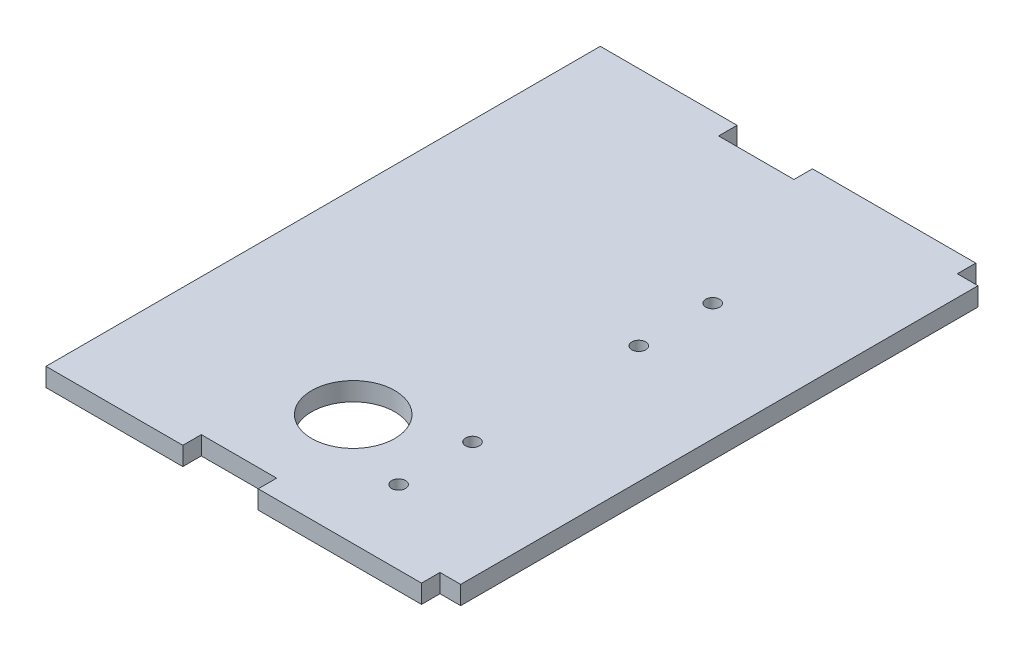
from build123d import *

# Parameters (mm, degrees)
SKETCH1_W           = 304.8
SKETCH1_H           = 355.6
SKETCH1_RX          = 28.575
SKETCH1_RY          = 28.573991153
BOSS_EXTRUDE1_DEPTH = 12.7
SKETCH2_R           = 4.7625
CUT_EXTRUDE1_DEPTH  = 12.7
SKETCH3_W           = 112.268
SKETCH3_H           = 12.7
BOSS_EXTRUDE2_DEPTH = 12.7
SKETCH5_W           = 38.383719954
SKETCH5_H           = 381
CUT_EXTRUDE2_DEPTH  = 13.7


with BuildPart() as part:
    # Sketch1 → Boss-Extrude1 (new body)
    with BuildSketch(Plane(origin=(0, 0, 0), x_dir=(1, 0, 0), z_dir=(0, 1, 0))):
        with Locations((152.4, 177.8)):
            Rectangle(SKETCH1_W, SKETCH1_H)
        with Locations(Location((166.724174942, 64.195003676), (0, 0, 0))):
            Ellipse(SKETCH1_RX, SKETCH1_RY, mode=Mode.SUBTRACT)
    extrude(amount=BOSS_EXTRUDE1_DEPTH)

    # Sketch2 → Cut-Extrude1 (cut)
    with BuildSketch(Plane.XZ):
        with Locations((224.028, -38.1)):
            Circle(SKETCH2_R)
        with Locations((224.028, -88.9)):
            Circle(SKETCH2_R)
        with Locations((224.028, -203.2)):
            Circle(SKETCH2_R)
        with Locations((224.028, -254)):
            Circle(SKETCH2_R)
    extrude(amount=-CUT_EXTRUDE1_DEPTH, mode=Mode.SUBTRACT)

    # Sketch3 → Boss-Extrude2 (add)
    with BuildSketch(Plane(origin=(0, 12.7, 0), x_dir=(1, 0, 0), z_dir=(0, 1, 0))):
        with Locations((70.358, 361.95)):
            Rectangle(SKETCH3_W, SKETCH3_H)
        with Locations((234.442, 361.95)):
            Rectangle(SKETCH3_W, SKETCH3_H)
        with Locations((234.442, -6.35)):
            Rectangle(SKETCH3_W, SKETCH3_H)
        with Locations((70.358, -6.35)):
            Rectangle(SKETCH3_W, SKETCH3_H)
    extrude(amount=-BOSS_EXTRUDE2_DEPTH)

    # Sketch5 → Cut-Extrude2 (cut, through all)
    with BuildSketch(Plane.XZ):
        with Locations((13.259015168, -177.8)):
            Rectangle(SKETCH5_W, SKETCH5_H)
    extrude(amount=-CUT_EXTRUDE2_DEPTH, mode=Mode.SUBTRACT)


solid = part.part
